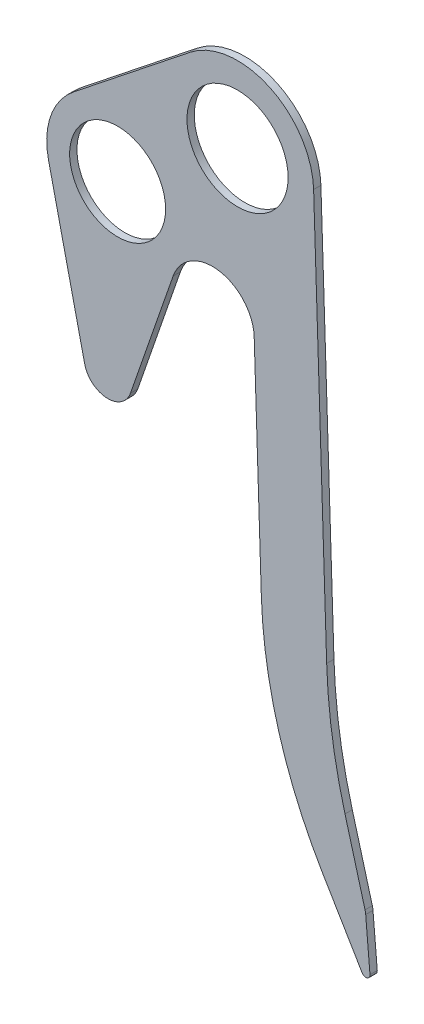
from build123d import *

# Parameters (mm, degrees)
SKETCH1_R      = 48.5
SKETCH1_R_2    = 46
EXTRUDE1_DEPTH = 7


with BuildPart() as part:
    # Sketch1 → Extrude1 (new body)
    with BuildSketch(Plane.XY):
        with BuildLine():
            Line((-181.296983893, -100.123158622), (-146.60541801, -252.204231237))
            ThreePointArc((-146.60541801, -252.204231237), (-125.550644715, -269.965422259), (-102.674010073, -254.621922903))
            Line((-102.674010073, -254.621922903), (-61.786520036, -136.878304089))
            ThreePointArc((-61.786520036, -136.878304089), (-17.984074435, -110.454979585), (15.979150749, -148.708680759))
            Line((15.979150749, -148.708680759), (22.803821631, -360))
            ThreePointArc((22.803821631, -360), (39.422409163, -464.1696592), (81.472905946, -560.912881546))
            Line((81.472905946, -560.912881546), (119.560838109, -625.042587939))
            ThreePointArc((119.560838109, -625.042587939), (124.22199896, -626.808768638), (126.985562325, -622.660451839))
            Line((126.985562325, -622.660451839), (122.910471509, -574.827683832))
            ThreePointArc((122.910471509, -574.827683832), (122.67212546, -573.014734487), (122.269195455, -571.231130949))
            Line((122.269195455, -571.231130949), (103.049494252, -501.215851748))
            ThreePointArc((103.049494252, -501.215851748), (90.834692996, -443.626181209), (85.473499156, -385))
            Line((85.473499156, -385), (72.961950117, 2.356657615))
            ThreePointArc((72.961950117, 2.356657615), (30.664556943, 66.247150486), (-45.416584246, 57.151849274))
            Line((-45.416584246, 57.151849274), (-157.305859298, -31.76266095))
            ThreePointArc((-157.305859298, -31.76266095), (-179.163336866, -62.481869477), (-181.296983893, -100.123158622))
        make_face()
        Circle(SKETCH1_R, mode=Mode.SUBTRACT)
        with Locations((-115, -85)):
            Circle(SKETCH1_R_2, mode=Mode.SUBTRACT)
    extrude(amount=EXTRUDE1_DEPTH)


solid = part.part
